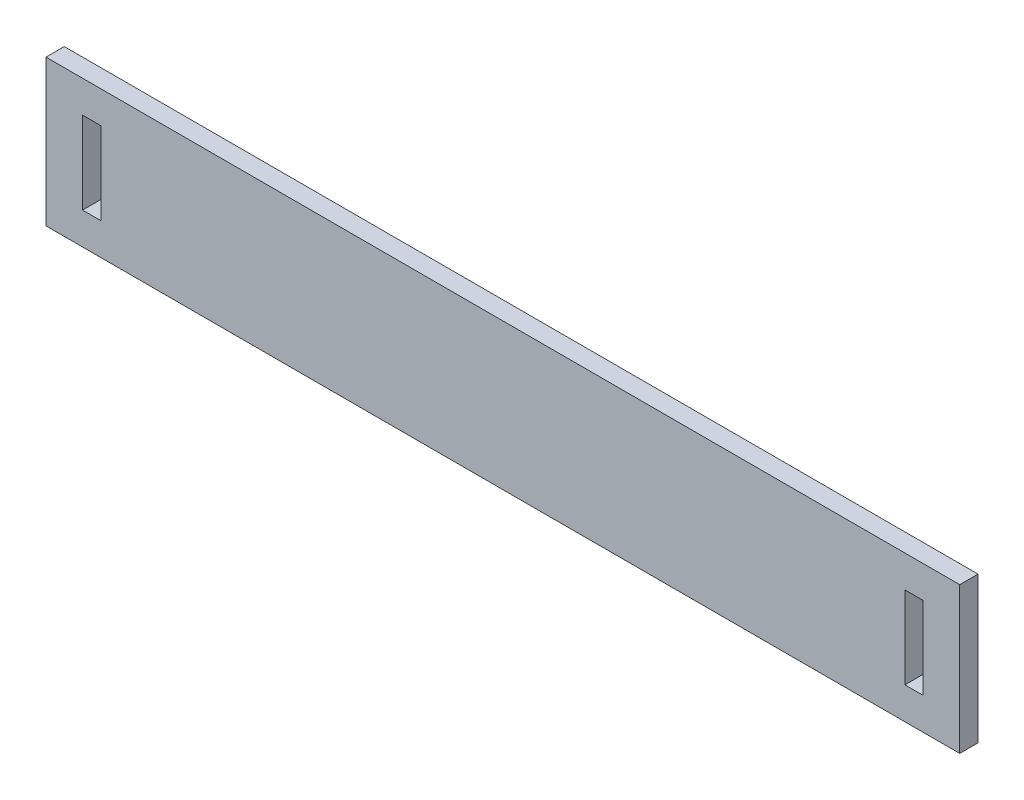
from build123d import *

# Parameters (mm, degrees)
SKETCH2_W           = 200
SKETCH2_H           = 32
BOSS_EXTRUDE1_DEPTH = 4
SKETCH3_W           = 4
SKETCH3_H           = 18
CUT_EXTRUDE1_DEPTH  = 4


with BuildPart() as part:
    # Sketch2 → Boss-Extrude1 (new body)
    with BuildSketch(Plane.XY):
        with Locations((37.882590882, 26.870095694)):
            Rectangle(SKETCH2_W, SKETCH2_H)
    extrude(amount=BOSS_EXTRUDE1_DEPTH)

    # Sketch3 → Cut-Extrude1 (cut)
    with BuildSketch(Plane.XY.offset(4)):
        with Locations((-52.117409118, 26.870095694)):
            Rectangle(SKETCH3_W, SKETCH3_H)
        with Locations((127.882590882, 26.870095694)):
            Rectangle(SKETCH3_W, SKETCH3_H)
    extrude(amount=-CUT_EXTRUDE1_DEPTH, mode=Mode.SUBTRACT)


solid = part.part
